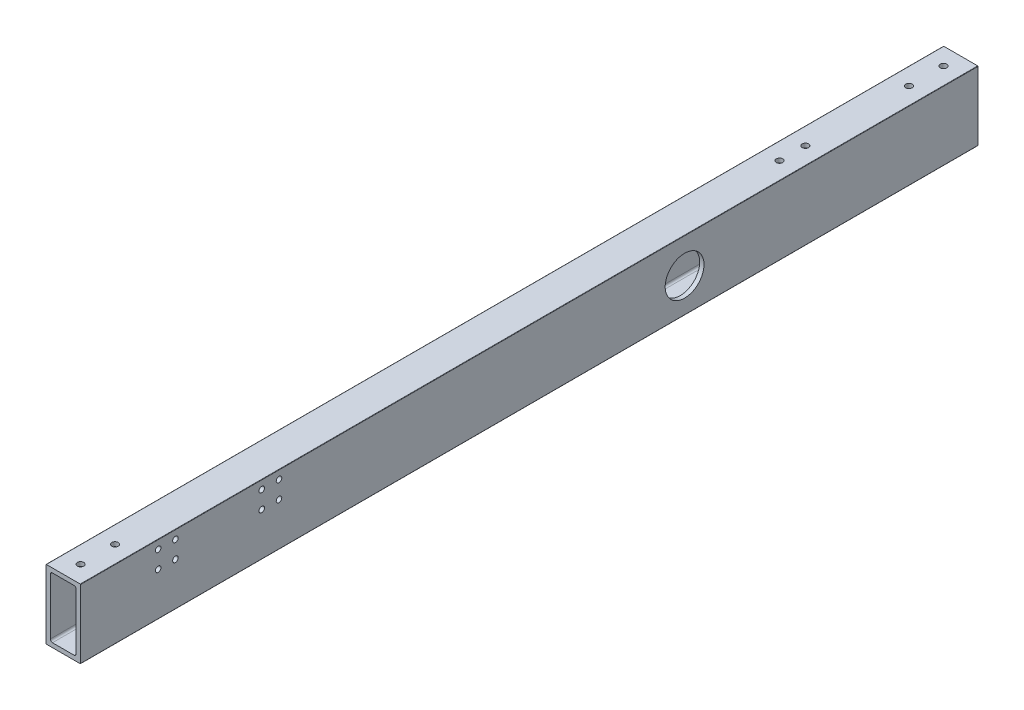
from build123d import *

# Parameters (mm, degrees)
BOSS_EXTRUDE1_DEPTH     = 660.4
SKETCH2_R               = 2.38125
CUT_EXTRUDE1_DEPTH      = 51.8
SKETCH5_R               = 14.2875
CUT_EXTRUDE2_DEPTH      = 26.4
SKETCH7_R               = 2.032
CUT_EXTRUDE3_DEPTH      = 1
CUT_EXTRUDE3_DEPTH_BACK = 26.4


with BuildPart() as part:
    # Sketch1 → Boss-Extrude1 (new body)
    with BuildSketch(Plane(origin=(0, 0, 0), x_dir=(-1, 0, 0), z_dir=(0, 0, -1))):
        with BuildLine():
            Line((0, 0.254), (0, 50.546))
            ThreePointArc((0, 50.546), (-0.074394878, 50.725605122), (-0.254, 50.8))
            Line((-0.254, 50.8), (-25.146, 50.8))
            ThreePointArc((-25.146, 50.8), (-25.325605122, 50.725605122), (-25.4, 50.546))
            Line((-25.4, 50.546), (-25.4, 0.254))
            ThreePointArc((-25.4, 0.254), (-25.325605122, 0.074394878), (-25.146, 0))
            Line((-25.146, 0), (-0.254, 0))
            ThreePointArc((-0.254, 0), (-0.074394878, 0.074394878), (0, 0.254))
        make_face()
        with BuildLine():
            Line((-3.175, 46.0375), (-3.175, 4.7625))
            ThreePointArc((-3.175, 4.7625), (-3.639967985, 3.639967985), (-4.7625, 3.175))
            Line((-4.7625, 3.175), (-20.6375, 3.175))
            ThreePointArc((-20.6375, 3.175), (-21.760032015, 3.639967985), (-22.225, 4.7625))
            Line((-22.225, 4.7625), (-22.225, 46.0375))
            ThreePointArc((-22.225, 46.0375), (-21.760032015, 47.160032015), (-20.6375, 47.625))
            Line((-20.6375, 47.625), (-4.7625, 47.625))
            ThreePointArc((-4.7625, 47.625), (-3.639967985, 47.160032015), (-3.175, 46.0375))
        make_face(mode=Mode.SUBTRACT)
    extrude(amount=-BOSS_EXTRUDE1_DEPTH)

    # Sketch2 → Cut-Extrude1 (cut, through all)
    with BuildSketch(Plane(origin=(0, 50.8, 0), x_dir=(1, 0, 0), z_dir=(0, 1, 0))):
        with Locations((12.7, -647.7)):
            Circle(SKETCH2_R)
        with Locations((12.7, -622.3)):
            Circle(SKETCH2_R)
        with Locations((12.7, -38.1)):
            Circle(SKETCH2_R)
        with Locations((12.7, -12.7)):
            Circle(SKETCH2_R)
        with Locations((12.7, -133.35)):
            Circle(SKETCH2_R)
        with Locations((12.7, -114.3)):
            Circle(SKETCH2_R)
    extrude(amount=-CUT_EXTRUDE1_DEPTH, mode=Mode.SUBTRACT)

    # Sketch5 → Cut-Extrude2 (cut, through all)
    with BuildSketch(Plane(origin=(25.4, 0, 0), x_dir=(0, 0, -1), z_dir=(1, 0, 0))):
        with Locations((-215.9, 25.146)):
            Circle(SKETCH5_R)
    extrude(amount=-CUT_EXTRUDE2_DEPTH, mode=Mode.SUBTRACT)

    # Sketch7 → Cut-Extrude3 (cut, two sides)
    with BuildSketch(Plane.ZY) as cut_extrude3_sk:
        with Locations((514.35, 44.45)):
            Circle(SKETCH7_R)
        with Locations((514.35, 31.75)):
            Circle(SKETCH7_R)
        with Locations((527.05, 31.75)):
            Circle(SKETCH7_R)
        with Locations((527.05, 44.45)):
            Circle(SKETCH7_R)
        with Locations((590.55, 44.45)):
            Circle(SKETCH7_R)
        with Locations((603.25, 44.45)):
            Circle(SKETCH7_R)
        with Locations((603.25, 31.75)):
            Circle(SKETCH7_R)
        with Locations((590.55, 31.75)):
            Circle(SKETCH7_R)
    extrude(amount=CUT_EXTRUDE3_DEPTH, mode=Mode.SUBTRACT)
    extrude(cut_extrude3_sk.sketch, amount=-CUT_EXTRUDE3_DEPTH_BACK, mode=Mode.SUBTRACT)


solid = part.part
